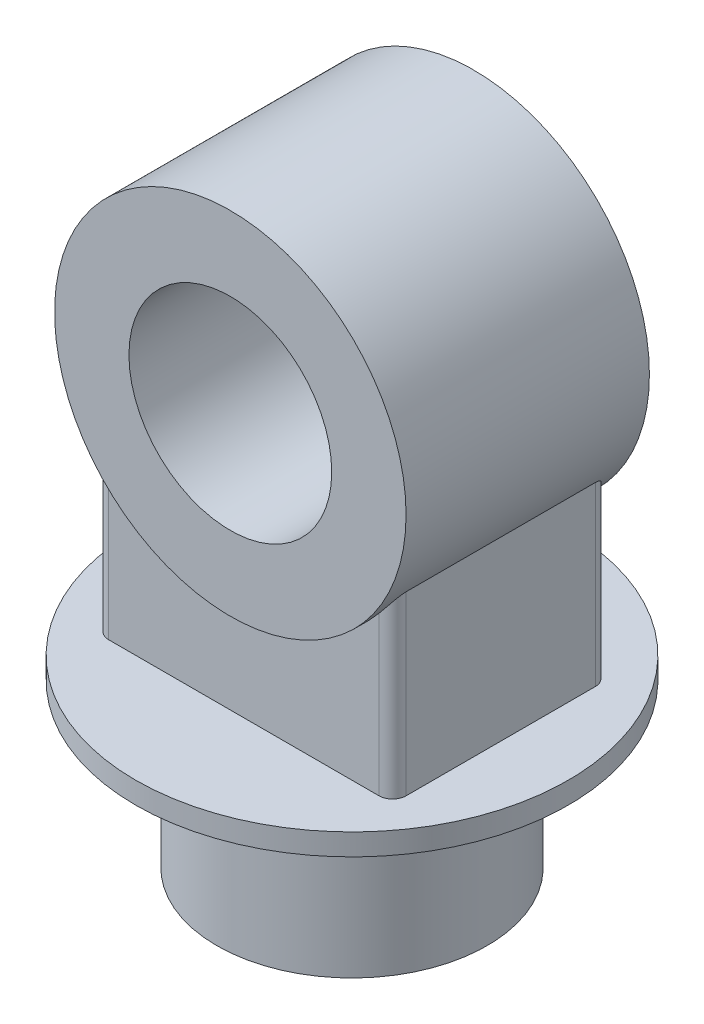
from build123d import *

# Parameters (mm, degrees)
SKETCH1_R                = 100
BOSS_EXTRUDE1_DEPTH      = 120
SKETCH2_R                = 160
BOSS_EXTRUDE2_DEPTH      = 16
SKETCH3_R                = 130
SKETCH3_R_2              = 75
BOSS_EXTRUDE3_DEPTH      = 90
BOSS_EXTRUDE4_REACH      = 402.125
BOSS_EXTRUDE4_END_RADIUS = 130
SKETCH4_W                = 220
SKETCH4_H                = 160
FILLET1_R                = 10


with BuildPart() as part:
    # Sketch1 → Boss-Extrude1 (new body)
    with BuildSketch(Plane(origin=(0, 0, 0), x_dir=(1, 0, 0), z_dir=(0, 1, 0))):
        with Locations(Location((0, 0, 0), (0, 0, 270))):
            Circle(SKETCH1_R)
    extrude(amount=BOSS_EXTRUDE1_DEPTH)

    # Sketch2 → Boss-Extrude2 (add)
    with BuildSketch(Plane(origin=(0, 120, 0), x_dir=(1, 0, 0), z_dir=(0, 1, 0))):
        with Locations(Location((0, 0, 0), (0, 0, 270))):
            Circle(SKETCH2_R)
    extrude(amount=BOSS_EXTRUDE2_DEPTH)



with BuildPart() as body_2:
    # Sketch3 → Boss-Extrude3 (new, symmetric)
    with BuildSketch(Plane.XY):
        with Locations(Location((0, 336, 0), (0, 0, 180))):
            Circle(SKETCH3_R)
        with Locations(Location((0, 336, 0), (0, 0, 180))):
            Circle(SKETCH3_R_2, mode=Mode.SUBTRACT)
    extrude(amount=BOSS_EXTRUDE3_DEPTH, both=True)


with BuildPart() as part_1:
    add(part.part)

    add(body_2.part)  # Boss-Extrude4 merges body 2
    # Boss-Extrude4: up to this cylinder (the profile starts outside it)
    boss_extrude4_end = Plane(origin=(0, 336, 0), z_dir=(0, 0, -1)) * Cylinder(BOSS_EXTRUDE4_END_RADIUS, 1065.25, mode=Mode.PRIVATE)
    # Sketch4 → Boss-Extrude4 (add, up to the surface)
    with BuildSketch(Plane(origin=(0, 136, 0), x_dir=(1, 0, 0), z_dir=(0, 1, 0)), mode=Mode.PRIVATE) as boss_extrude4_sk1:
        Rectangle(SKETCH4_W, SKETCH4_H)
    boss_extrude4_tool1 = extrude(boss_extrude4_sk1.sketch, amount=BOSS_EXTRUDE4_REACH, mode=Mode.PRIVATE) - boss_extrude4_end
    add(boss_extrude4_tool1.solids().sort_by_distance((0, 136, 0))[0])

    # Fillet1
    fillet1_edges = [part_1.edges().sort_by_distance(p)[0] for p in [
        (110, 201.358983849, -80),
        (110, 201.358983849, 80),
        (-110, 201.358983849, -80),
        (-110, 201.358983849, 80),
    ]]
    fillet(fillet1_edges, radius=FILLET1_R)


solid = part_1.part
